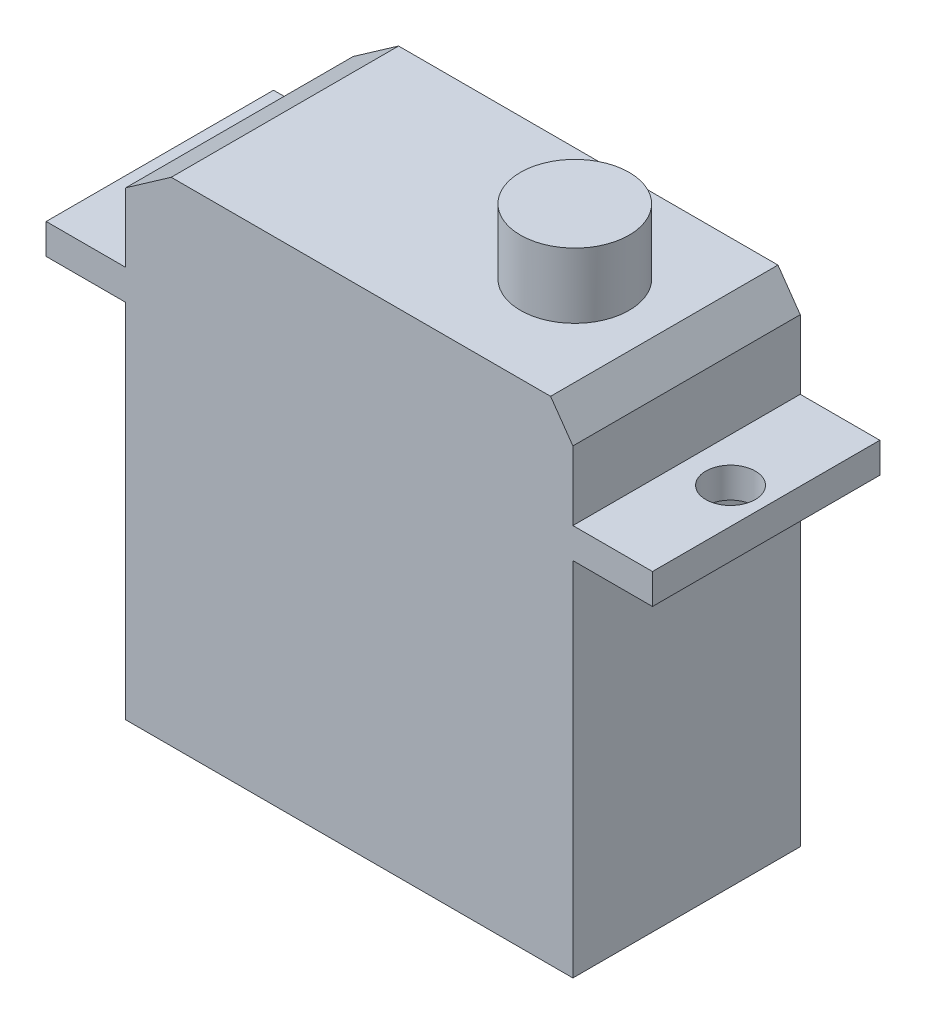
from build123d import *

# Parameters (mm, degrees)
BOSS_EXTRUDE1_DEPTH       = 7.5
SKETCH2_R                 = 3.587141307
BOSS_EXTRUDE2_DEPTH       = 4.3
F_4_CLEARANCE_HOLE1_D     = 3.2639
F_4_CLEARANCE_HOLE1_DEPTH = 5.84
F_4_CLEARANCE_HOLE1_TIP   = 0.980574487


with BuildPart() as part:
    # Sketch1 → Boss-Extrude1 (new, symmetric)
    with BuildSketch(Plane.XY):
        Polygon((-14.75, 11.925), (-20, 11.925), (-20, 13.925), (-14.75, 13.925), (-14.75, 18.474377385), (-11.75, 20.575), (13.27912821, 20.575), (14.75, 18.474377385), (14.75, 13.925), (20, 13.925), (20, 11.925), (14.75, 11.925), (14.75, -11.925), (-14.75, -11.925), align=None)
    extrude(amount=BOSS_EXTRUDE1_DEPTH, both=True)

    # Sketch2 → Boss-Extrude2 (add)
    with BuildSketch(Plane(origin=(0, 20.575, 0), x_dir=(1, 0, 0), z_dir=(0, 1, 0))):
        with Locations((7.375, 0)):
            Circle(SKETCH2_R)
    extrude(amount=BOSS_EXTRUDE2_DEPTH)

    # 4 Clearance Hole1
    with Locations(Plane(origin=(0, 13.925, 0), x_dir=(1, 0, 0), z_dir=(0, 1, 0))):
        with Locations((-17.65, 0), (17.65, 0)):
            Hole(F_4_CLEARANCE_HOLE1_D / 2, depth=F_4_CLEARANCE_HOLE1_DEPTH)
            with Locations((0, 0, -(F_4_CLEARANCE_HOLE1_DEPTH + F_4_CLEARANCE_HOLE1_TIP / 2))):  # 118° drill point
                Cone(0, F_4_CLEARANCE_HOLE1_D / 2, F_4_CLEARANCE_HOLE1_TIP, mode=Mode.SUBTRACT)


solid = part.part
